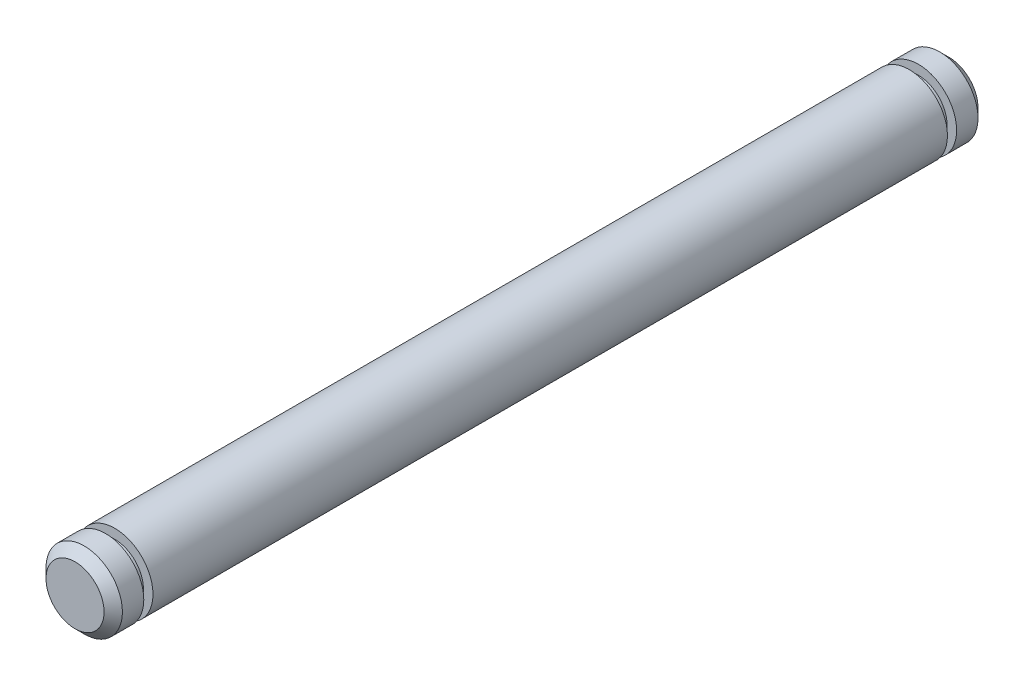
from build123d import *

# Parameters (mm, degrees)
SKETCH1_R                = 1.5875
BOSS_EXTRUDE1_DEPTH      = 16.50746
SKETCH2_R                = 1.19126
BOSS_EXTRUDE2_DEPTH      = 0.381
SKETCH3_R                = 1.5875
BOSS_EXTRUDE3_DEPTH      = 1.27
CHAMFER1_SIZE            = 0.381
CHAMFER1_OF_MIRROR1_SIZE = 0.381


with BuildPart() as part:
    # Sketch1 → Boss-Extrude1 (new body, symmetric)
    with BuildSketch(Plane.XY):
        Circle(SKETCH1_R)
    extrude(amount=BOSS_EXTRUDE1_DEPTH, both=True)

    # Sketch2 → Boss-Extrude2 (add)
    with BuildSketch(Plane.XY.offset(16.50746)):
        Circle(SKETCH2_R)
    boss_extrude2 = extrude(amount=BOSS_EXTRUDE2_DEPTH)

    # Sketch3 → Boss-Extrude3 (add)
    with BuildSketch(Plane.XY.offset(16.88846)):
        Circle(SKETCH3_R)
    boss_extrude3 = extrude(amount=BOSS_EXTRUDE3_DEPTH)

    # Chamfer1
    chamfer1_edges = [part.edges().sort_by_distance(p)[0] for p in [
        (-1.5875, 0, 18.15846),
    ]]
    chamfer(chamfer1_edges, length=CHAMFER1_SIZE)

    # Mirror1: Boss-Extrude2, Boss-Extrude3 across plane
    add(boss_extrude2.mirror(Plane.XY))
    add(boss_extrude3.mirror(Plane.XY))

    # Chamfer1 of Mirror1
    chamfer1_of_mirror1_edges = [part.edges().sort_by_distance(p)[0] for p in [
        (-1.5875, 0, -18.15846),
    ]]
    chamfer(chamfer1_of_mirror1_edges, length=CHAMFER1_OF_MIRROR1_SIZE)


solid = part.part
